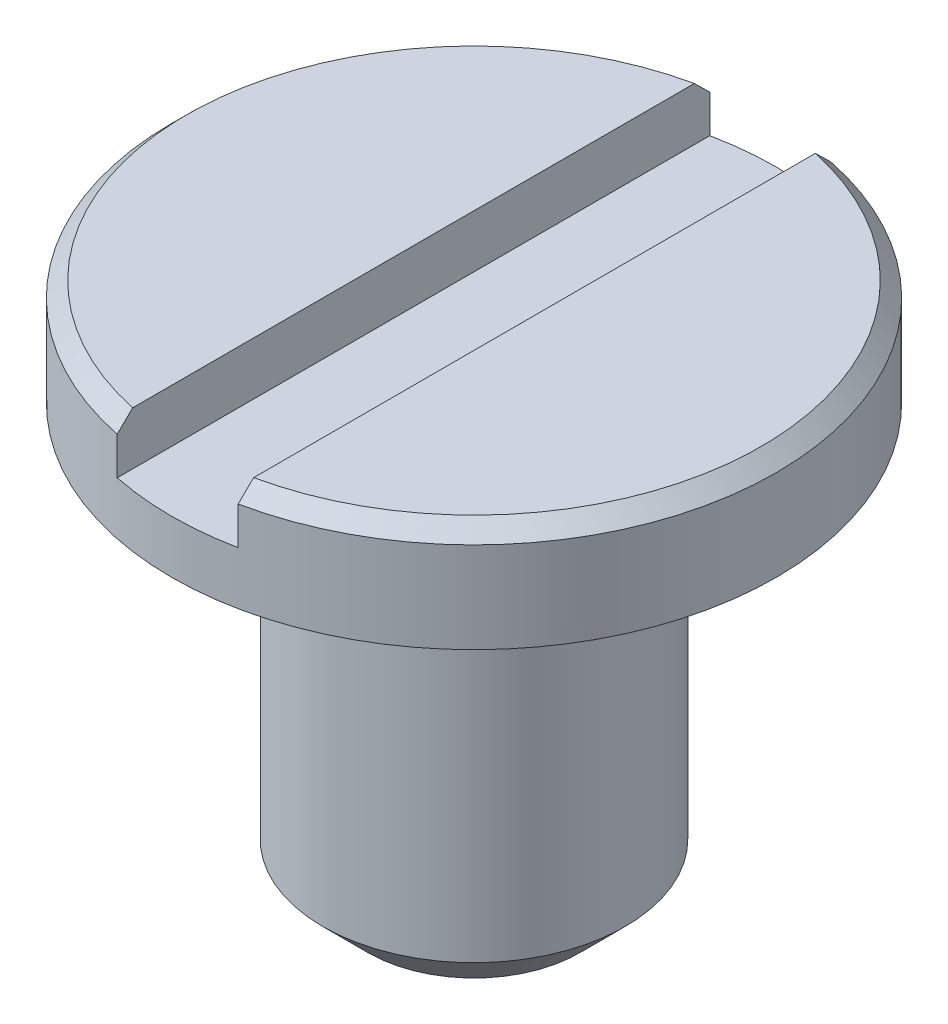
from build123d import *

# Parameters (mm, degrees)
SKETCH1_R               = 1
BOSS_EXTRUDE1_DEPTH     = 0.35
SKETCH2_R               = 0.5
BOSS_EXTRUDE2_DEPTH     = 1.4
CHAMFER1_SIZE           = 0.05
CHAMFER2_SIZE           = 0.15
CUT_EXTRUDE1_DEPTH      = 2
CUT_EXTRUDE1_DEPTH_BACK = 2


with BuildPart() as part:
    # Sketch1 → Boss-Extrude1 (new body)
    with BuildSketch(Plane(origin=(0, 0, 0), x_dir=(1, 0, 0), z_dir=(0, 1, 0))):
        Circle(SKETCH1_R)
    extrude(amount=BOSS_EXTRUDE1_DEPTH)

    # Sketch2 → Boss-Extrude2 (add)
    with BuildSketch(Plane(origin=(0, 0, 0), x_dir=(1, 0, 0), z_dir=(0, 1, 0))):
        Circle(SKETCH2_R)
    extrude(amount=-BOSS_EXTRUDE2_DEPTH)

    # Chamfer1
    chamfer1_edges = [part.edges().sort_by_distance(p)[0] for p in [
        (-1, 0.35, 0),
    ]]
    chamfer(chamfer1_edges, length=CHAMFER1_SIZE)

    # Chamfer2
    chamfer2_edges = [part.edges().sort_by_distance(p)[0] for p in [
        (-0.5, -1.4, 0),
    ]]
    chamfer(chamfer2_edges, length=CHAMFER2_SIZE)

    # Sketch3 → Cut-Extrude1 (cut, two sides)
    with BuildSketch(Plane.XY) as cut_extrude1_sk:
        Polygon((-0.2, 0.35), (0, 0.35), (0.2, 0.35), (0.2, 0.175), (0, 0.175), (-0.2, 0.175), align=None)
    extrude(amount=CUT_EXTRUDE1_DEPTH, mode=Mode.SUBTRACT)
    extrude(cut_extrude1_sk.sketch, amount=-CUT_EXTRUDE1_DEPTH_BACK, mode=Mode.SUBTRACT)


solid = part.part
